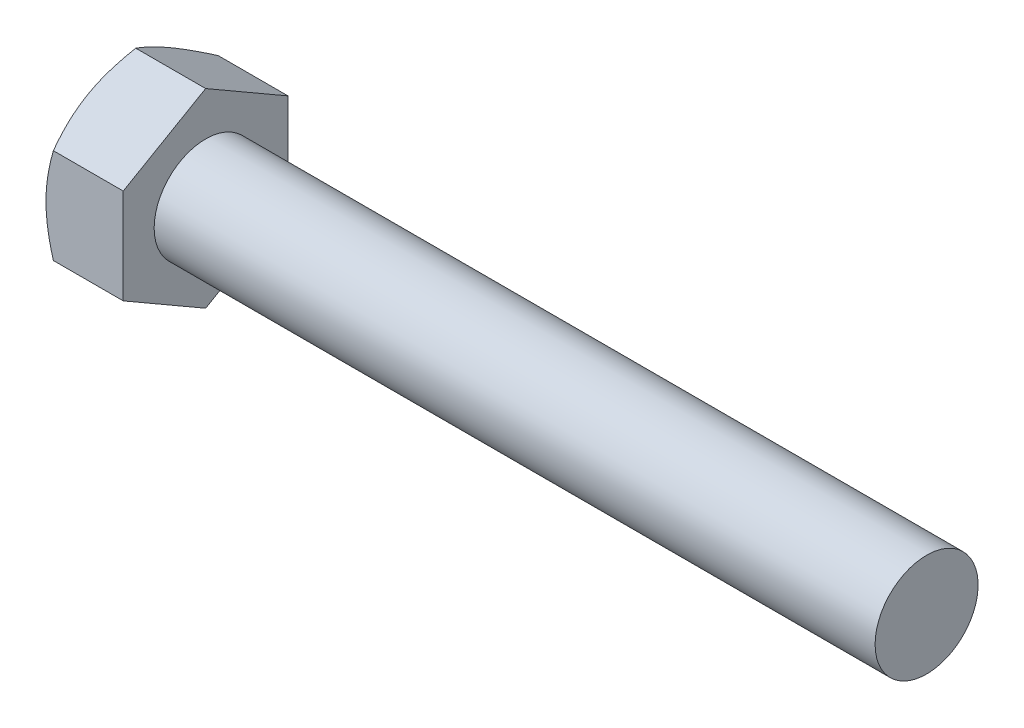
from build123d import *

# Parameters (mm, degrees)
SKETCH2_R     = 9.330254042
HEX_DIE_DEPTH = 7.5
SKETCH4_R     = 7
INDENT_DEPTH  = 0.9375


with BuildPart() as part:
    # BodySke → Base-Revolve (revolve)
    with BuildSketch(Plane.XY, mode=Mode.PRIVATE) as base_revolve_sk:
        Polygon((7.5, 5), (7.5, 9.237875289), (0.714687631, 9.237875289), (0, 8), (0, 0), (77.5, 0), (77.5, 5), align=None)
    revolve(base_revolve_sk.sketch.rotate(Axis((-25.4, 0, 0), (1, 0, 0)), 90), axis=Axis((-25.4, 0, 0), (1, 0, 0)))  # turned: the seam where the file's is

    # Sketch2 → Hex-Die (cut)
    with BuildSketch(Plane(origin=(0, 0, 0), x_dir=(0, 0, -1), z_dir=(1, 0, 0))):
        Circle(SKETCH2_R)
        Polygon((-8, 4.618802174), (0, 9.237604347), (8, 4.618802174), (8, -4.618802174), (0, -9.237604347), (-8, -4.618802174), align=None, mode=Mode.SUBTRACT)
    extrude(amount=HEX_DIE_DEPTH, mode=Mode.SUBTRACT)

    # Sketch4 → Indent (cut)
    with BuildSketch(Plane(origin=(0, 0, 0), x_dir=(0, 0, -1), z_dir=(1, 0, 0))):
        Circle(SKETCH4_R)
    extrude(amount=INDENT_DEPTH, mode=Mode.SUBTRACT)


solid = part.part
